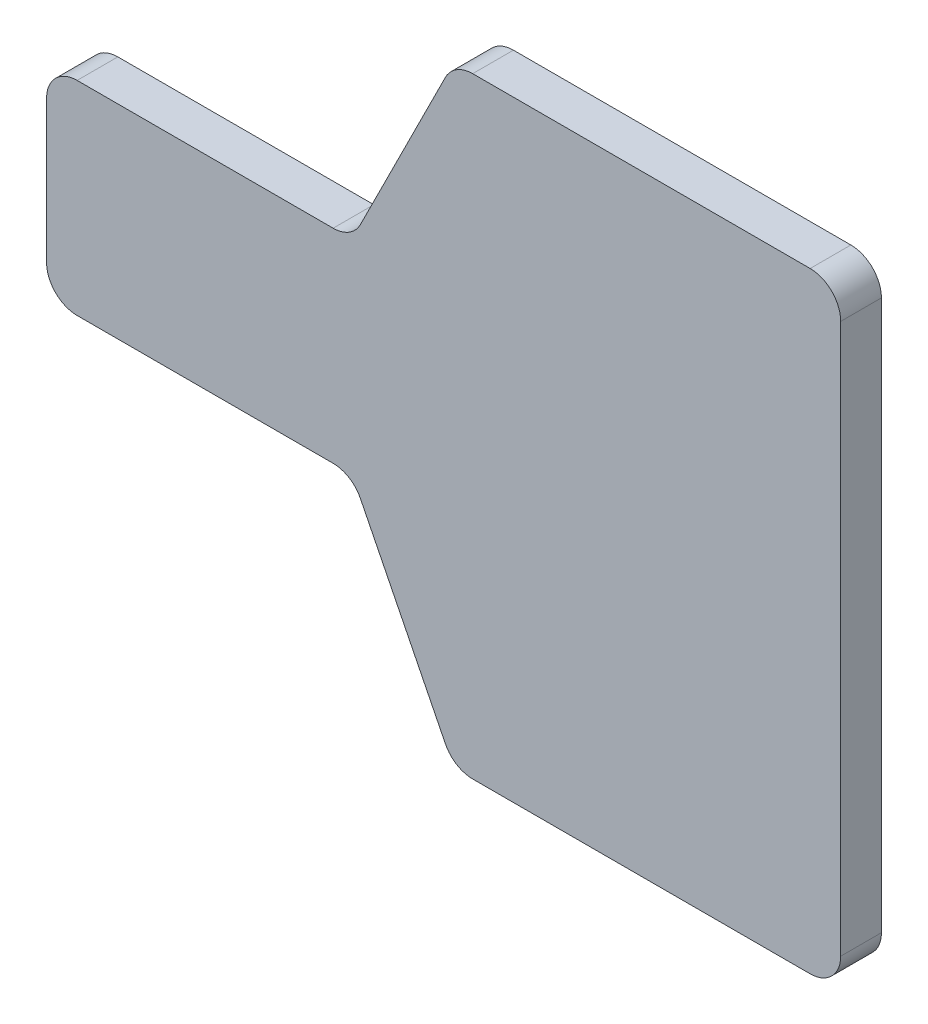
from build123d import *

# Parameters (mm, degrees)
BOSS_EXTRUDE2_DEPTH = 4
FILLET7_R           = 3


with BuildPart() as part:
    # Sketch1 → Boss-Extrude2 (new body)
    with BuildSketch(Plane.XY):
        Polygon((-30, -10), (-30, 10), (0, 10), (10, 30), (30, 30), (48, 30), (48, -30), (30, -30), (10, -30), (0, -10), align=None)
    extrude(amount=BOSS_EXTRUDE2_DEPTH)

    # Fillet7
    fillet7_edges = [part.edges().sort_by_distance(p)[0] for p in [
        (-30, -10, 2),
        (-30, 10, 2),
        (0, 10, 2),
        (10, 30, 2),
        (48, 30, 2),
        (48, -30, 2),
        (10, -30, 2),
        (0, -10, 2),
    ]]
    fillet(fillet7_edges, radius=FILLET7_R)


solid = part.part
